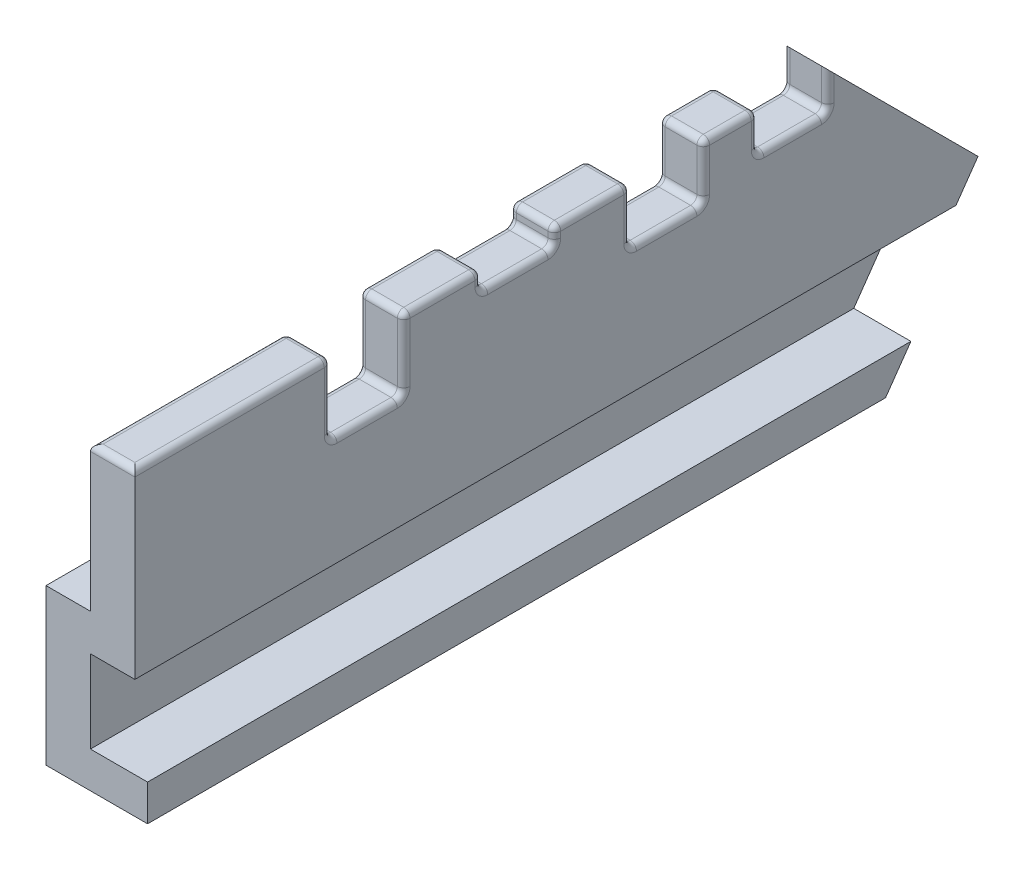
from build123d import *

# Parameters (mm, degrees)
BOSS_EXTRUDE1_DEPTH     = 13.28
CUT_EXTRUDE1_DEPTH      = 14.53406443
CUT_EXTRUDE1_DEPTH_BACK = 14.53406443
CUT_EXTRUDE5_DEPTH      = 0.29
CUT_EXTRUDE6_DEPTH      = 1.13
CUT_EXTRUDE7_DEPTH      = 0.87
CUT_EXTRUDE8_DEPTH      = 0.6
FILLET1_R               = 0.1


with BuildPart() as part:
    # Sketch1 → Boss-Extrude1 (new body)
    with BuildSketch(Plane.XY):
        Polygon((0, 0), (0, 2.28), (0.7, 2.28), (0.7, -0.58), (0, -0.58), (0, -1.88), (0.9, -1.88), (0.9, -2.45), (-0.7, -2.45), (-0.7, 0), align=None)
    extrude(amount=BOSS_EXTRUDE1_DEPTH)

    # Sketch2 → Cut-Extrude1 (cut, two sides)
    with BuildSketch(Plane(origin=(0, 0, 0), x_dir=(0, 0, -1), z_dir=(1, 0, 0))) as cut_extrude1_sk:
        Polygon((0.8, -2.75), (0.8, -0.085), (0.8, 2.58), (-2.665, 2.58), (0, -0.085), (-1.866053089, -2.75), align=None)
    extrude(amount=CUT_EXTRUDE1_DEPTH, mode=Mode.SUBTRACT)
    extrude(cut_extrude1_sk.sketch, amount=-CUT_EXTRUDE1_DEPTH_BACK, mode=Mode.SUBTRACT)

    # 3DSketch1 → Cut-Extrude5 (cut)
    with BuildSketch(Plane(origin=(0.7, 2.28, 7.8225), x_dir=(-0.5199469468957453, 0, -0.8541985556144386), z_dir=(0, 1, 0))):
        Polygon((0, 0), (0.982328339, -0.597938989), (1.346291202, 0), (0.363962863, 0.597938989), align=None)
    extrude(amount=-CUT_EXTRUDE5_DEPTH, mode=Mode.SUBTRACT)

    # 3DSketch1_3 → Cut-Extrude6 (cut)
    with BuildSketch(Plane(origin=(0, 2.28, 10.196397445), x_dir=(0.5199469468957453, 0, -0.8541985556144386), z_dir=(0, 1, 0))):
        Polygon((0, 0), (0.982328339, 0.597938989), (1.346291202, 0), (0.363962863, -0.597938989), align=None)
    extrude(amount=-CUT_EXTRUDE6_DEPTH, mode=Mode.SUBTRACT)

    # 3DSketch1_4 → Cut-Extrude7 (cut)
    with BuildSketch(Plane(origin=(0, 2.28, 5.478611146), x_dir=(0.519345577670118, 0, -0.8545643164528294), z_dir=(0, 1, 0))):
        Polygon((0, 0), (0.984308217, 0.598195022), (1.347850122, 0), (0.363541904, -0.598195022), align=None)
    extrude(amount=-CUT_EXTRUDE7_DEPTH, mode=Mode.SUBTRACT)

    # 3DSketch1_5 → Cut-Extrude8 (cut)
    with BuildSketch(Plane(origin=(0, 2.28, 3.471184381), x_dir=(0.5347339426738265, 0, -0.8450204793686985), z_dir=(0, 1, 0))):
        Polygon((0, 0), (0.934748456, 0.591514336), (1.309062216, 0), (0.37431376, -0.591514336), align=None)
    extrude(amount=-CUT_EXTRUDE8_DEPTH, mode=Mode.SUBTRACT)

    # Fillet1
    fillet1_edges = [part.edges().sort_by_distance(p)[0] for p in [
        (0.7, 2.28, 3.898985455),
        (0, 1.41, 4.902698837),
        (0.35, 1.41, 4.326786528),
        (0.35, 2.28, 5.478611146),
        (0.35, 1.41, 5.478611146),
        (0, 1.845, 5.478611146),
        (0.7, 1.41, 4.902698837),
        (0.7, 1.845, 5.478611146),
        (0, 1.845, 4.326786528),
        (0.35, 2.28, 4.326786528),
        (0.7, 1.845, 4.326786528),
        (0, 1.68, 2.918092191),
        (0.35, 1.68, 2.365),
        (0.35, 2.28, 3.471184381),
        (0, 1.98, 2.365),
        (0.7, 1.98, 2.365),
        (0.35, 1.68, 3.471184381),
        (0, 1.98, 3.471184381),
        (0.7, 1.68, 2.918092191),
        (0.7, 1.98, 3.471184381),
        (0, 2.28, 11.738198723),
        (0.7, 2.28, 11.738198723),
        (0.35, 2.28, 13.28),
        (0, 2.28, 6.075555573),
        (0.7, 2.28, 6.075555573),
        (0.35, 1.99, 7.8225),
        (0, 1.99, 7.2475),
        (0.35, 2.28, 6.6725),
        (0.35, 2.28, 7.8225),
        (0, 2.135, 7.8225),
        (0, 2.135, 6.6725),
        (0.7, 1.99, 7.2475),
        (0.7, 2.135, 7.8225),
        (0.35, 1.99, 6.6725),
        (0.7, 2.135, 6.6725),
        (0, 2.28, 8.434448723),
        (0.7, 2.28, 8.434448723),
        (0, 1.15, 9.621397445),
        (0.35, 1.15, 9.046397445),
        (0.35, 2.28, 10.196397445),
        (0, 1.715, 9.046397445),
        (0.35, 2.28, 9.046397445),
        (0.7, 1.715, 9.046397445),
        (0.35, 1.15, 10.196397445),
        (0, 1.715, 10.196397445),
        (0.7, 1.15, 9.621397445),
        (0.7, 1.715, 10.196397445),
        (0, 2.28, 3.898985455),
    ]]
    fillet(fillet1_edges, radius=FILLET1_R)


solid = part.part
